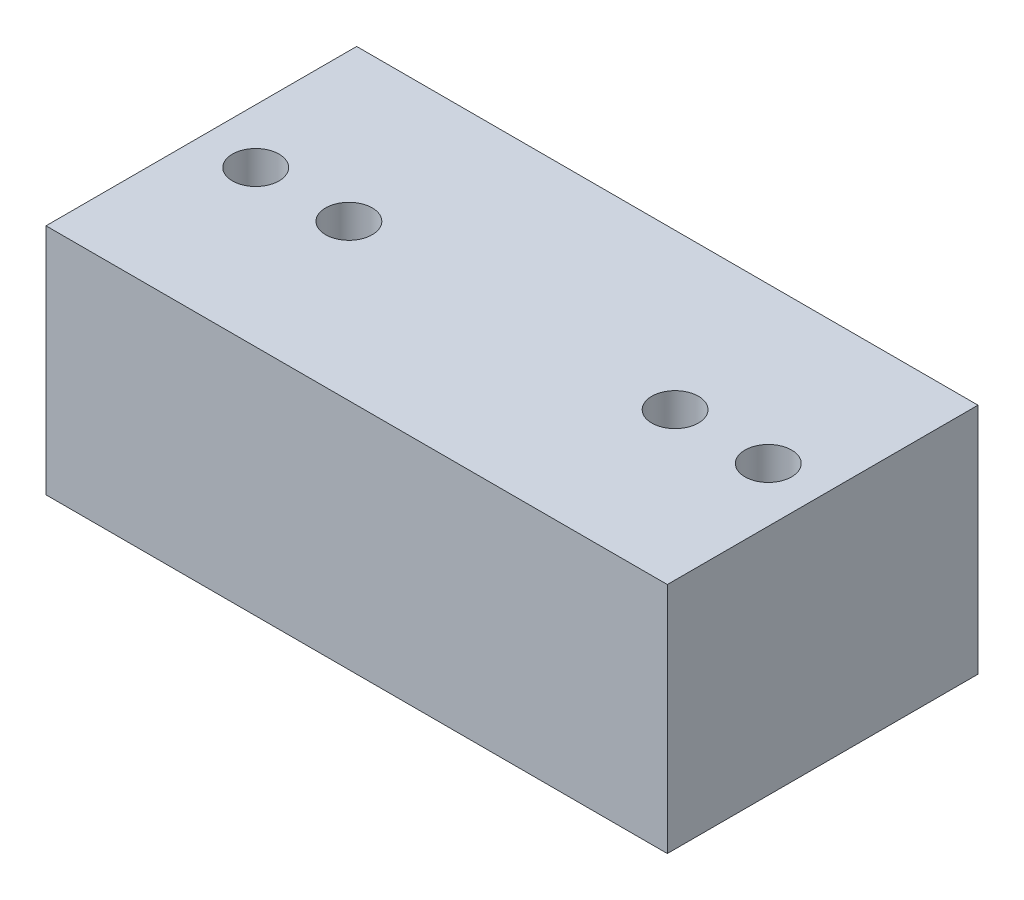
from build123d import *

# Parameters (mm, degrees)
SKETCH1_W           = 80
SKETCH1_H           = 40
SKETCH1_R           = 3
BOSS_EXTRUDE1_DEPTH = 30
SKETCH2_R           = 3
CUT_EXTRUDE1_DEPTH  = 15


with BuildPart() as part:
    # Sketch1 → Boss-Extrude1 (new body)
    with BuildSketch(Plane(origin=(0, 0, 0), x_dir=(1, 0, 0), z_dir=(0, 1, 0))):
        with Locations((0, 11.100547393)):
            Rectangle(SKETCH1_W, SKETCH1_H)
        with Locations(Location((-33, 11.100547393, 0), (0, 0, 270))):  # turned: the seam where the file's is
            Circle(SKETCH1_R, mode=Mode.SUBTRACT)
        with Locations(Location((33, 11.100547393, 0), (0, 0, 90))):  # turned: the seam where the file's is
            Circle(SKETCH1_R, mode=Mode.SUBTRACT)
    extrude(amount=BOSS_EXTRUDE1_DEPTH)

    # Sketch2 → Cut-Extrude1 (cut)
    with BuildSketch(Plane(origin=(0, 30, 0), x_dir=(-1, 0, 0), z_dir=(0, 1, 0))):
        with Locations(Location((21, -11.100547393, 0), (0, 0, 90))):  # turned: the seam where the file's is
            Circle(SKETCH2_R)
        with Locations(Location((-21, -11.100547393, 0), (0, 0, 270))):  # turned: the seam where the file's is
            Circle(SKETCH2_R)
    extrude(amount=-CUT_EXTRUDE1_DEPTH, mode=Mode.SUBTRACT)


solid = part.part
